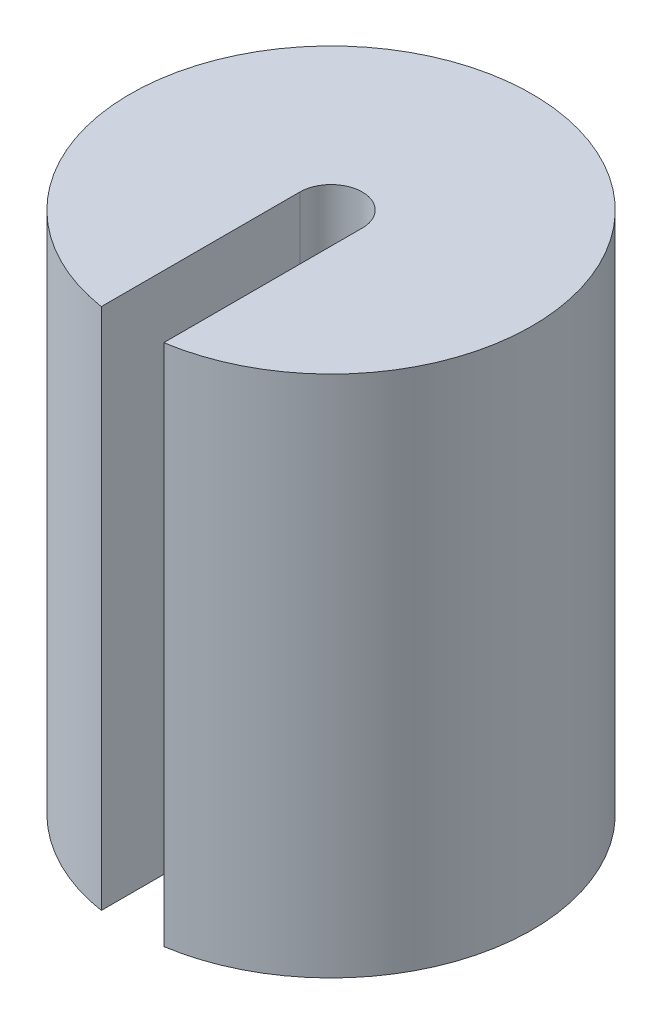
from build123d import *

# Parameters (mm, degrees)
SKETCH1_R           = 20.75
BOSS_EXTRUDE1_DEPTH = 54
CUT_EXTRUDE1_DEPTH  = 60.6


with BuildPart() as part:
    # Sketch1 → Boss-Extrude1 (new body)
    with BuildSketch(Plane(origin=(0, 0, 0), x_dir=(1, 0, 0), z_dir=(0, 1, 0))):
        Circle(SKETCH1_R)
    extrude(amount=BOSS_EXTRUDE1_DEPTH)

    # Sketch2 → Cut-Extrude1 (cut)
    with BuildSketch(Plane(origin=(0, 54, 0), x_dir=(1, 0, 0), z_dir=(0, 1, 0))):
        with BuildLine():
            Line((-3.225, 0), (-3.225, -23.125803827))
            Line((-3.225, -23.125803827), (3.225, -23.125803827))
            Line((3.225, -23.125803827), (3.225, 0))
            ThreePointArc((3.225, 0), (0, 3.225), (-3.225, 0))
        make_face()
    extrude(amount=-CUT_EXTRUDE1_DEPTH, mode=Mode.SUBTRACT)


solid = part.part
